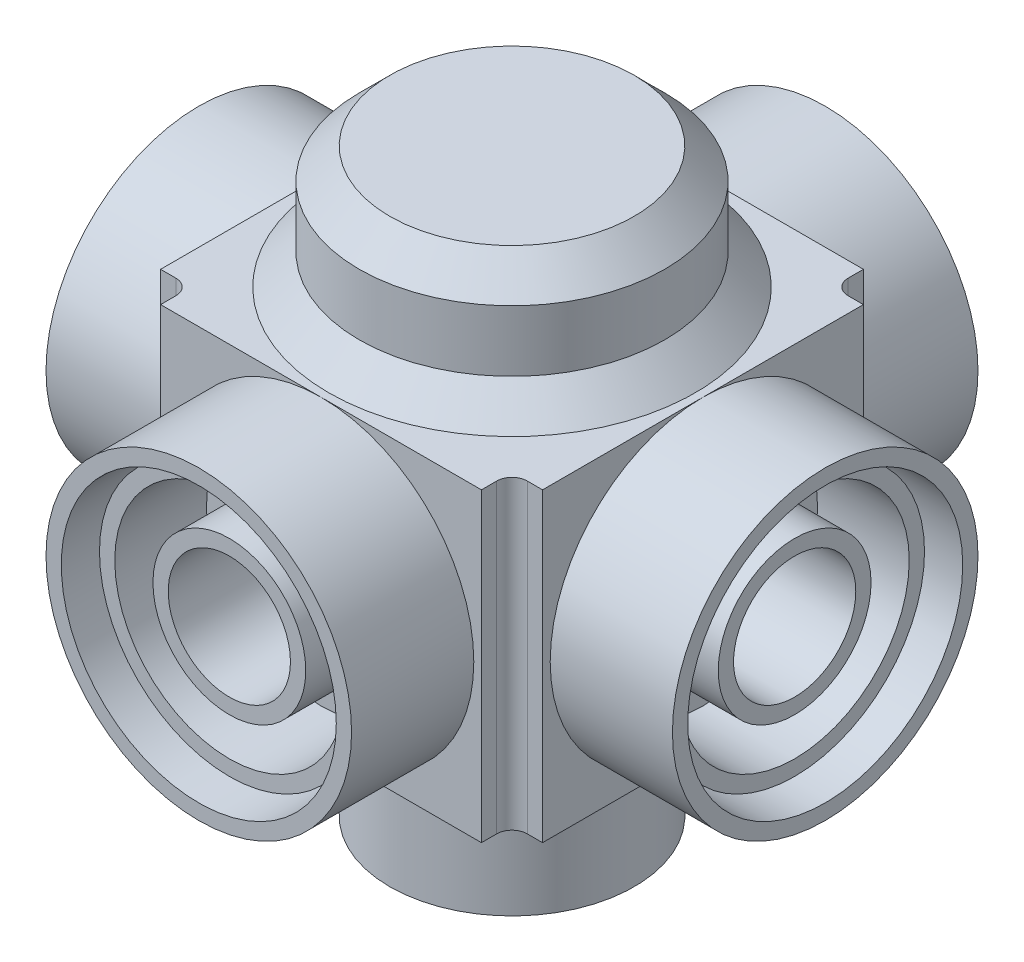
from build123d import *

# Parameters (mm, degrees)
SKETCH1_R           = 100
BOSS_EXTRUDE1_DEPTH = 80
SKETCH2_W           = 250
SKETCH2_H           = 250
BOSS_EXTRUDE2_DEPTH = 200
SKETCH3_R           = 80
SKETCH3_R_2         = 70
BOSS_EXTRUDE3_DEPTH = 100
CHAMFER1_SIZE       = 20
SKETCH4_W           = 20
SKETCH4_H           = 200
CUT_EXTRUDE1_DEPTH  = 20
SKETCH5_R           = 100
SKETCH5_R_2         = 90
BOSS_EXTRUDE4_DEPTH = 80
SKETCH6_R           = 85
SKETCH6_R_2         = 75
SKETCH6_R_3         = 50
SKETCH6_R_4         = 40
BOSS_EXTRUDE5_DEPTH = 60
CIRPATTERN1_COUNT   = 4
FILLET1_R           = 10
SKETCH7_R           = 12.5
CUT_EXTRUDE2_DEPTH  = 123


with BuildPart() as part:
    # Sketch1 → Boss-Extrude1 (new body)
    with BuildSketch(Plane(origin=(0, 0, 0), x_dir=(1, 0, 0), z_dir=(0, 1, 0))):
        Circle(SKETCH1_R)
    extrude(amount=-BOSS_EXTRUDE1_DEPTH)

    # Sketch2 → Boss-Extrude2 (add)
    with BuildSketch(Plane.XZ.offset(80)):
        Rectangle(SKETCH2_W, SKETCH2_H)
    extrude(amount=BOSS_EXTRUDE2_DEPTH)

    # Sketch3 → Boss-Extrude3 (add)
    with BuildSketch(Plane.XZ.offset(280)):
        Circle(SKETCH3_R)
        Circle(SKETCH3_R_2, mode=Mode.SUBTRACT)
    extrude(amount=BOSS_EXTRUDE3_DEPTH)

    # Chamfer1
    chamfer1_edges = [part.edges().sort_by_distance(p)[0] for p in [
        (-100, 0, 0),
        (-100, -80, 0),
    ]]
    chamfer(chamfer1_edges, length=CHAMFER1_SIZE)

    # Sketch4 → Cut-Extrude1 (cut)
    with BuildSketch(Plane(origin=(125, 0, 0), x_dir=(0, 0, -1), z_dir=(1, 0, 0))):
        with Locations((-115, -180)):
            Rectangle(SKETCH4_W, SKETCH4_H)
        with Locations((115, -180)):
            Rectangle(SKETCH4_W, SKETCH4_H)
    cut_extrude1 = extrude(amount=-CUT_EXTRUDE1_DEPTH, mode=Mode.SUBTRACT)

    # Sketch5 → Boss-Extrude4 (add)
    with BuildSketch(Plane(origin=(125, 0, 0), x_dir=(0, 0, -1), z_dir=(1, 0, 0))):
        with Locations((0, -180)):
            Circle(SKETCH5_R)
        with Locations((0, -180)):
            Circle(SKETCH5_R_2, mode=Mode.SUBTRACT)
    boss_extrude4 = extrude(amount=BOSS_EXTRUDE4_DEPTH)

    # Sketch6 → Boss-Extrude5 (add)
    with BuildSketch(Plane(origin=(125, 0, 0), x_dir=(0, 0, -1), z_dir=(1, 0, 0))):
        with Locations((0, -180)):
            Circle(SKETCH6_R)
        with Locations((0, -180)):
            Circle(SKETCH6_R_2, mode=Mode.SUBTRACT)
        with Locations((0, -180)):
            Circle(SKETCH6_R_3)
        with Locations((0, -180)):
            Circle(SKETCH6_R_4, mode=Mode.SUBTRACT)
    boss_extrude5 = extrude(amount=BOSS_EXTRUDE5_DEPTH)

    # CirPattern1: Cut-Extrude1, Boss-Extrude4, Boss-Extrude5 ×4 about axis
    cirpattern1_axis = Axis((0, 0, 0), (0, 1, 0))
    for i in range(1, CIRPATTERN1_COUNT):
        add(cut_extrude1.rotate(cirpattern1_axis, i * 360 / CIRPATTERN1_COUNT), mode=Mode.SUBTRACT)
        add(boss_extrude4.rotate(cirpattern1_axis, i * 360 / CIRPATTERN1_COUNT))
        add(boss_extrude5.rotate(cirpattern1_axis, i * 360 / CIRPATTERN1_COUNT))

    # Fillet1
    fillet1_edges = [part.edges().sort_by_distance(p)[0] for p in [
        (-105, -180, 105),
        (-105, -180, -105),
        (105, -180, 105),
        (105, -180, -105),
    ]]
    fillet(fillet1_edges, radius=FILLET1_R)

    # Sketch7 → Cut-Extrude2 (cut)
    with BuildSketch(Plane.XY):
        with Locations((0, -330)):
            Circle(SKETCH7_R)
    extrude(amount=-CUT_EXTRUDE2_DEPTH, mode=Mode.SUBTRACT)


solid = part.part
